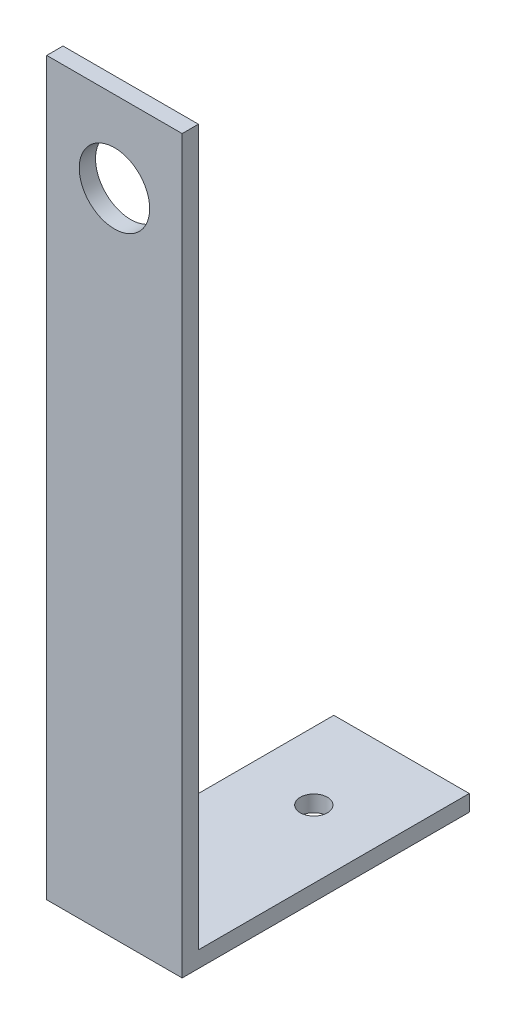
from build123d import *

# Parameters (mm, degrees)
CROQUIS1_W              = 50
CROQUIS1_H              = 100
SALIENTE_EXTRUIR1_DEPTH = 6
CROQUIS2_W              = 50
CROQUIS2_H              = 6
SALIENTE_EXTRUIR2_DEPTH = 270
CROQUIS3_R              = 13
CORTAR_EXTRUIR1_DEPTH   = 107
SKETCH1_R               = 5
CUT_EXTRUDE1_DEPTH      = 10


with BuildPart() as part:
    # Croquis1 → Saliente-Extruir1 (new body)
    with BuildSketch(Plane(origin=(0, 0, 0), x_dir=(1, 0, 0), z_dir=(0, 1, 0))):
        Rectangle(CROQUIS1_W, CROQUIS1_H)
    extrude(amount=SALIENTE_EXTRUIR1_DEPTH)

    # Croquis2 → Saliente-Extruir2 (add)
    with BuildSketch(Plane.XZ):
        with Locations((0, 53)):
            Rectangle(CROQUIS2_W, CROQUIS2_H)
    extrude(amount=-SALIENTE_EXTRUIR2_DEPTH)

    # Croquis3 → Cortar-Extruir1 (cut, through all)
    with BuildSketch(Plane.XY.offset(56)):
        with Locations((0, 240)):
            Circle(CROQUIS3_R)
    extrude(amount=-CORTAR_EXTRUIR1_DEPTH, mode=Mode.SUBTRACT)

    # Sketch1 → Cut-Extrude1 (cut)
    with BuildSketch(Plane(origin=(0, 6, 0), x_dir=(1, 0, 0), z_dir=(0, 1, 0))):
        with Locations((0, 17.616363636)):
            Circle(SKETCH1_R)
    extrude(amount=-CUT_EXTRUDE1_DEPTH, mode=Mode.SUBTRACT)


solid = part.part
